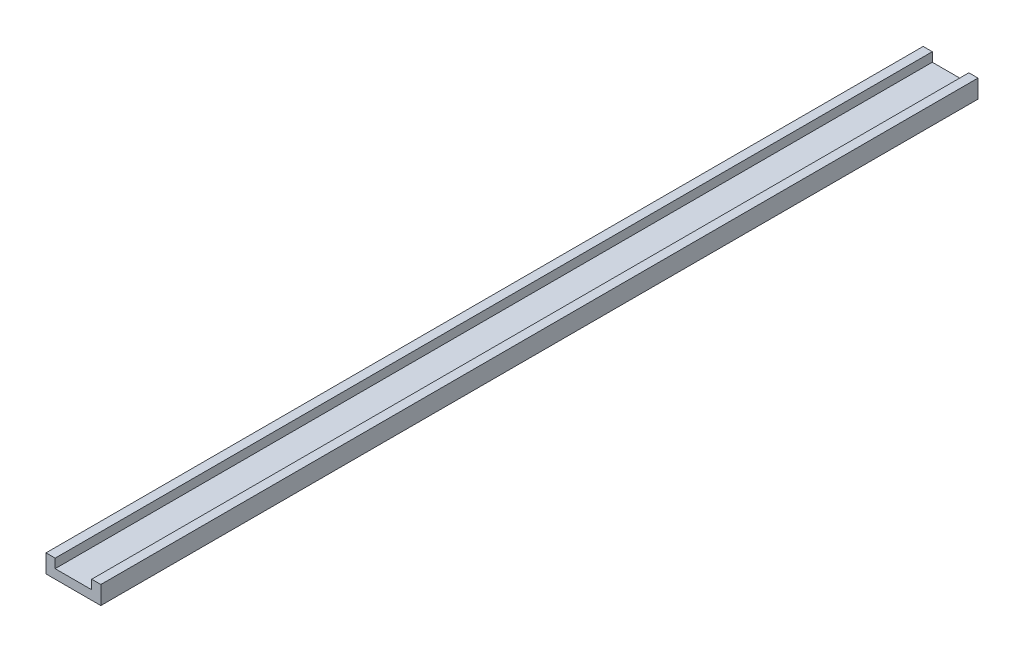
from build123d import *

# Parameters (mm, degrees)
SKETCH1_W           = 19.05
SKETCH1_H           = 6.35
BOSS_EXTRUDE1_DEPTH = 304.8
SKETCH2_W           = 12.7
SKETCH2_H           = 3.175
CUT_EXTRUDE1_DEPTH  = 304.8


with BuildPart() as part:
    # Sketch1 → Boss-Extrude1 (new body)
    with BuildSketch(Plane.XY):
        with Locations((9.525, 3.175)):
            Rectangle(SKETCH1_W, SKETCH1_H)
    extrude(amount=BOSS_EXTRUDE1_DEPTH)

    # Sketch2 → Cut-Extrude1 (cut)
    with BuildSketch(Plane.XY.offset(304.8)):
        with Locations((9.525, 4.7625)):
            Rectangle(SKETCH2_W, SKETCH2_H)
    extrude(amount=-CUT_EXTRUDE1_DEPTH, mode=Mode.SUBTRACT)


solid = part.part
